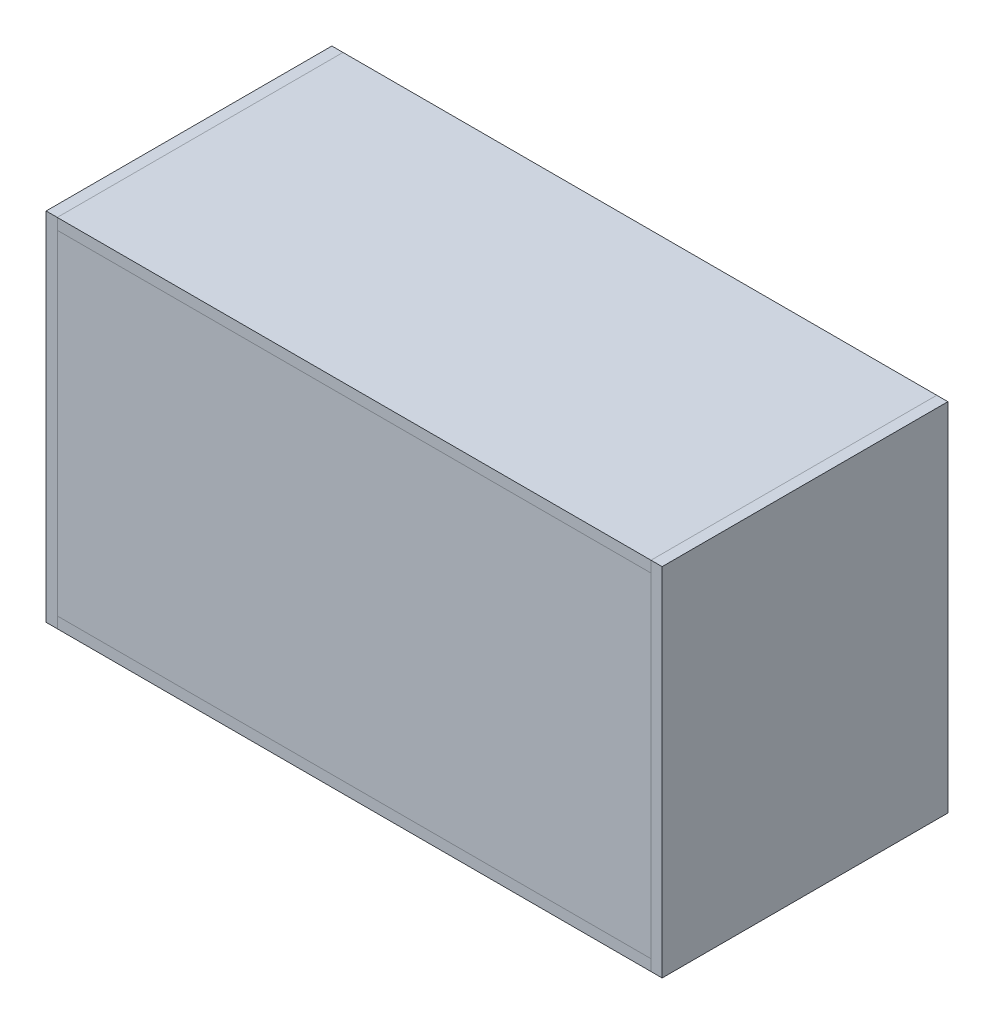
from build123d import *

# Parameters (mm, degrees)
SKETCH1_W    = 1016
SKETCH1_H    = 488.95
BOTTOM_DEPTH = 19.05
SKETCH2_W    = 488.95
SKETCH2_H    = 609.6
SIDE_DEPTH   = 19.05
SKETCH3_W    = 1016
SKETCH3_H    = 488.95
TOP_DEPTH    = 19.05
SKETCH6_W    = 1016
SKETCH6_H    = 571.5
FRONT_DEPTH  = 19.05


with BuildPart() as part:
    # Sketch1 → bottom (new body)
    with BuildSketch(Plane(origin=(0, 0, 0), x_dir=(1, 0, 0), z_dir=(0, 1, 0))):
        Rectangle(SKETCH1_W, SKETCH1_H)
    extrude(amount=-BOTTOM_DEPTH)


with BuildPart() as body_2:
    # Sketch2 → side (new body)
    with BuildSketch(Plane.ZY.offset(508)):
        with Locations((0, 285.75)):
            Rectangle(SKETCH2_W, SKETCH2_H)
    extrude(amount=SIDE_DEPTH)


with BuildPart() as body_3:
    # Mirror1: mirrored copy
    add(body_2.part.mirror(Plane(origin=(0, 0, 0), x_dir=(0, 0, 1), z_dir=(1, 0, 0))))


with BuildPart() as body_4:
    # Sketch3 → top (new body)
    with BuildSketch(Plane(origin=(0, 590.55, 0), x_dir=(1, 0, 0), z_dir=(0, 1, 0))):
        Rectangle(SKETCH3_W, SKETCH3_H)
    extrude(amount=-TOP_DEPTH)


with BuildPart() as body_5:
    # Sketch6 → front (new body)
    with BuildSketch(Plane.XY.offset(244.475)):
        with Locations((0, 285.75)):
            Rectangle(SKETCH6_W, SKETCH6_H)
    extrude(amount=-FRONT_DEPTH)


with BuildPart() as body_6:
    # Mirror2: mirrored copy
    add(body_5.part.mirror(Plane.XY))


solid = Compound([part.part, body_2.part, body_3.part, body_4.part, body_5.part, body_6.part])
